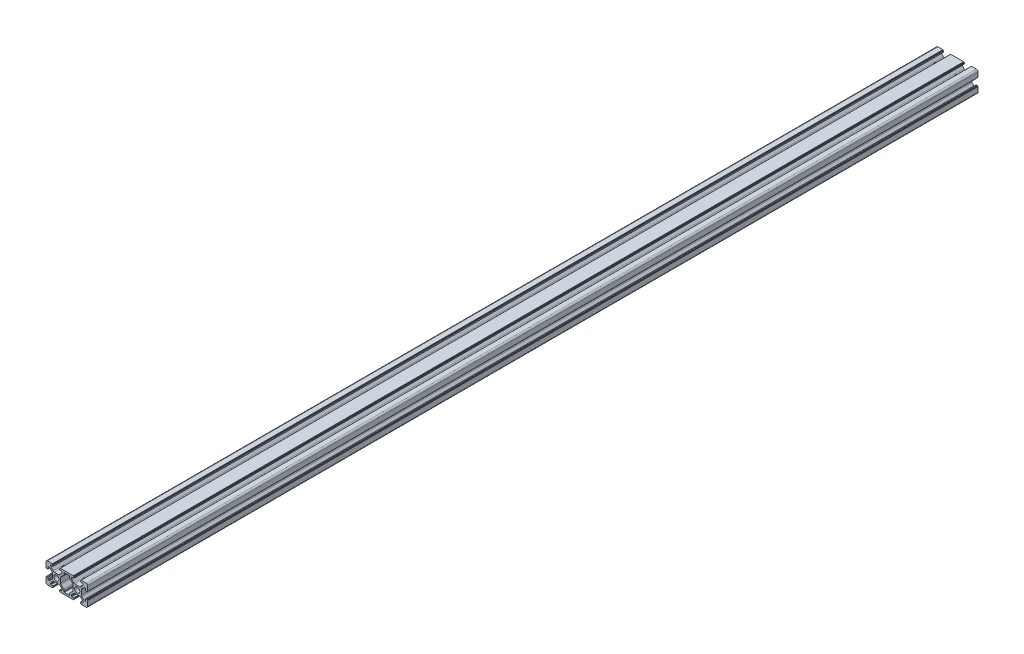
from build123d import *

# Parameters (mm, degrees)
SKETCH1_R                     = 2.5
BOSS_EXTRUDE2_DEPTH           = 856
SKETCH3_W                     = 2.75
SKETCH3_H                     = 13.9
M5_CLEARANCE_HOLE1_AT_2_COUNT = 2
M5_CLEARANCE_HOLE1_AT_2_PITCH = 20
M5_CLEARANCE_HOLE1_AT_3_COUNT = 2
M5_CLEARANCE_HOLE1_AT_3_PITCH = 838
M5_CLEARANCE_HOLE1_AT_4_COUNT = 2
M5_CLEARANCE_HOLE1_AT_4_PITCH = 838.238629508


with BuildPart() as part:
    # Sketch1 → Boss-Extrude2 (new body)
    with BuildSketch(Plane.XY):
        with BuildLine():
            Line((1.5, 0), (6.2, 0))
            ThreePointArc((6.2, 0), (6.341421356, 0.058578644), (6.4, 0.2))
            Line((6.4, 0.2), (6.4, 0.3))
            ThreePointArc((6.4, 0.3), (6.458578644, 0.441421356), (6.6, 0.5))
            Line((6.6, 0.5), (6.7, 0.5))
            ThreePointArc((6.7, 0.5), (6.841421356, 0.558578644), (6.9, 0.7))
            Line((6.9, 0.7), (6.9, 1.5))
            ThreePointArc((6.9, 1.5), (6.812132034, 1.712132034), (6.6, 1.8))
            Line((6.6, 1.8), (4.8, 1.8))
            ThreePointArc((4.8, 1.8), (4.587867966, 1.887867966), (4.5, 2.1))
            Line((4.5, 2.1), (4.5, 2.818019485))
            ThreePointArc((4.5, 2.818019485), (4.614180701, 3.392044633), (4.939339828, 3.878679656))
            Line((4.939339828, 3.878679656), (6.721320344, 5.660660172))
            ThreePointArc((6.721320344, 5.660660172), (7.207955367, 5.985819299), (7.781980515, 6.1))
            Line((7.781980515, 6.1), (12.218019485, 6.1))
            ThreePointArc((12.218019485, 6.1), (12.792044633, 5.985819299), (13.278679656, 5.660660172))
            Line((13.278679656, 5.660660172), (15.060660172, 3.878679656))
            ThreePointArc((15.060660172, 3.878679656), (15.385819299, 3.392044633), (15.5, 2.818019485))
            Line((15.5, 2.818019485), (15.5, 2.1))
            ThreePointArc((15.5, 2.1), (15.412132034, 1.887867966), (15.2, 1.8))
            Line((15.2, 1.8), (13.4, 1.8))
            ThreePointArc((13.4, 1.8), (13.187867966, 1.712132034), (13.1, 1.5))
            Line((13.1, 1.5), (13.1, 0.7))
            ThreePointArc((13.1, 0.7), (13.158578644, 0.558578644), (13.3, 0.5))
            Line((13.3, 0.5), (13.4, 0.5))
            ThreePointArc((13.4, 0.5), (13.541421356, 0.441421356), (13.6, 0.3))
            Line((13.6, 0.3), (13.6, 0.2))
            ThreePointArc((13.6, 0.2), (13.658578644, 0.058578644), (13.8, 0))
            Line((13.8, 0), (26.2, 0))
            ThreePointArc((26.2, 0), (26.341421356, 0.058578644), (26.4, 0.2))
            Line((26.4, 0.2), (26.4, 0.3))
            ThreePointArc((26.4, 0.3), (26.458578644, 0.441421356), (26.6, 0.5))
            Line((26.6, 0.5), (26.7, 0.5))
            ThreePointArc((26.7, 0.5), (26.841421356, 0.558578644), (26.9, 0.7))
            Line((26.9, 0.7), (26.9, 1.5))
            ThreePointArc((26.9, 1.5), (26.812132034, 1.712132034), (26.6, 1.8))
            Line((26.6, 1.8), (24.8, 1.8))
            ThreePointArc((24.8, 1.8), (24.587867966, 1.887867966), (24.5, 2.1))
            Line((24.5, 2.1), (24.5, 2.818019485))
            ThreePointArc((24.5, 2.818019485), (24.614180701, 3.392044633), (24.939339828, 3.878679656))
            Line((24.939339828, 3.878679656), (26.721320344, 5.660660172))
            ThreePointArc((26.721320344, 5.660660172), (27.207955367, 5.985819299), (27.781980515, 6.1))
            Line((27.781980515, 6.1), (32.218019485, 6.1))
            ThreePointArc((32.218019485, 6.1), (32.792044633, 5.985819299), (33.278679656, 5.660660172))
            Line((33.278679656, 5.660660172), (35.060660172, 3.878679656))
            ThreePointArc((35.060660172, 3.878679656), (35.385819299, 3.392044633), (35.5, 2.818019485))
            Line((35.5, 2.818019485), (35.5, 2.1))
            ThreePointArc((35.5, 2.1), (35.412132034, 1.887867966), (35.2, 1.8))
            Line((35.2, 1.8), (33.4, 1.8))
            ThreePointArc((33.4, 1.8), (33.187867966, 1.712132034), (33.1, 1.5))
            Line((33.1, 1.5), (33.1, 0.7))
            ThreePointArc((33.1, 0.7), (33.158578644, 0.558578644), (33.3, 0.5))
            Line((33.3, 0.5), (33.4, 0.5))
            ThreePointArc((33.4, 0.5), (33.541421356, 0.441421356), (33.6, 0.3))
            Line((33.6, 0.3), (33.6, 0.2))
            ThreePointArc((33.6, 0.2), (33.658578644, 0.058578644), (33.8, 0))
            Line((33.8, 0), (38.5, 0))
            ThreePointArc((38.5, 0), (39.560660172, 0.439339828), (40, 1.5))
            Line((40, 1.5), (40, 6.2))
            ThreePointArc((40, 6.2), (39.941421356, 6.341421356), (39.8, 6.4))
            Line((39.8, 6.4), (39.7, 6.4))
            ThreePointArc((39.7, 6.4), (39.558578644, 6.458578644), (39.5, 6.6))
            Line((39.5, 6.6), (39.5, 6.7))
            ThreePointArc((39.5, 6.7), (39.441421356, 6.841421356), (39.3, 6.9))
            Line((39.3, 6.9), (38.5, 6.9))
            ThreePointArc((38.5, 6.9), (38.287867966, 6.812132034), (38.2, 6.6))
            Line((38.2, 6.6), (38.2, 4.8))
            ThreePointArc((38.2, 4.8), (38.112132034, 4.587867966), (37.9, 4.5))
            Line((37.9, 4.5), (37.181980515, 4.5))
            ThreePointArc((37.181980515, 4.5), (36.607955367, 4.614180701), (36.121320344, 4.939339828))
            Line((36.121320344, 4.939339828), (34.339339828, 6.721320344))
            ThreePointArc((34.339339828, 6.721320344), (34.014180701, 7.207955367), (33.9, 7.781980515))
            Line((33.9, 7.781980515), (33.9, 12.218019485))
            ThreePointArc((33.9, 12.218019485), (34.014180701, 12.792044633), (34.339339828, 13.278679656))
            Line((34.339339828, 13.278679656), (36.121320344, 15.060660172))
            ThreePointArc((36.121320344, 15.060660172), (36.607955367, 15.385819299), (37.181980515, 15.5))
            Line((37.181980515, 15.5), (37.9, 15.5))
            ThreePointArc((37.9, 15.5), (38.112132034, 15.412132034), (38.2, 15.2))
            Line((38.2, 15.2), (38.2, 13.4))
            ThreePointArc((38.2, 13.4), (38.287867966, 13.187867966), (38.5, 13.1))
            Line((38.5, 13.1), (39.3, 13.1))
            ThreePointArc((39.3, 13.1), (39.441421356, 13.158578644), (39.5, 13.3))
            Line((39.5, 13.3), (39.5, 13.4))
            ThreePointArc((39.5, 13.4), (39.558578644, 13.541421356), (39.7, 13.6))
            Line((39.7, 13.6), (39.8, 13.6))
            ThreePointArc((39.8, 13.6), (39.941421356, 13.658578644), (40, 13.8))
            Line((40, 13.8), (40, 18.5))
            ThreePointArc((40, 18.5), (39.560660172, 19.560660172), (38.5, 20))
            Line((38.5, 20), (33.8, 20))
            ThreePointArc((33.8, 20), (33.658578644, 19.941421356), (33.6, 19.8))
            Line((33.6, 19.8), (33.6, 19.7))
            ThreePointArc((33.6, 19.7), (33.541421356, 19.558578644), (33.4, 19.5))
            Line((33.4, 19.5), (33.3, 19.5))
            ThreePointArc((33.3, 19.5), (33.158578644, 19.441421356), (33.1, 19.3))
            Line((33.1, 19.3), (33.1, 18.5))
            ThreePointArc((33.1, 18.5), (33.187867966, 18.287867966), (33.4, 18.2))
            Line((33.4, 18.2), (35.2, 18.2))
            ThreePointArc((35.2, 18.2), (35.412132034, 18.112132034), (35.5, 17.9))
            Line((35.5, 17.9), (35.5, 17.181980515))
            ThreePointArc((35.5, 17.181980515), (35.385819299, 16.607955367), (35.060660172, 16.121320344))
            Line((35.060660172, 16.121320344), (33.278679656, 14.339339828))
            ThreePointArc((33.278679656, 14.339339828), (32.792044633, 14.014180701), (32.218019485, 13.9))
            Line((32.218019485, 13.9), (27.781980515, 13.9))
            ThreePointArc((27.781980515, 13.9), (27.207955367, 14.014180701), (26.721320344, 14.339339828))
            Line((26.721320344, 14.339339828), (24.939339828, 16.121320344))
            ThreePointArc((24.939339828, 16.121320344), (24.614180701, 16.607955367), (24.5, 17.181980515))
            Line((24.5, 17.181980515), (24.5, 17.9))
            ThreePointArc((24.5, 17.9), (24.587867966, 18.112132034), (24.8, 18.2))
            Line((24.8, 18.2), (26.6, 18.2))
            ThreePointArc((26.6, 18.2), (26.812132034, 18.287867966), (26.9, 18.5))
            Line((26.9, 18.5), (26.9, 19.3))
            ThreePointArc((26.9, 19.3), (26.841421356, 19.441421356), (26.7, 19.5))
            Line((26.7, 19.5), (26.6, 19.5))
            ThreePointArc((26.6, 19.5), (26.458578644, 19.558578644), (26.4, 19.7))
            Line((26.4, 19.7), (26.4, 19.8))
            ThreePointArc((26.4, 19.8), (26.341421356, 19.941421356), (26.2, 20))
            Line((26.2, 20), (13.8, 20))
            ThreePointArc((13.8, 20), (13.658578644, 19.941421356), (13.6, 19.8))
            Line((13.6, 19.8), (13.6, 19.7))
            ThreePointArc((13.6, 19.7), (13.541421356, 19.558578644), (13.4, 19.5))
            Line((13.4, 19.5), (13.3, 19.5))
            ThreePointArc((13.3, 19.5), (13.158578644, 19.441421356), (13.1, 19.3))
            Line((13.1, 19.3), (13.1, 18.2))
            Line((13.1, 18.2), (15.3, 18.2))
            ThreePointArc((15.3, 18.2), (15.512132034, 18.112132034), (15.6, 17.9))
            Line((15.6, 17.9), (15.6, 17.281980515))
            ThreePointArc((15.6, 17.281980515), (15.485819299, 16.707955367), (15.160660172, 16.221320344))
            Line((15.160660172, 16.221320344), (13.278679656, 14.339339828))
            ThreePointArc((13.278679656, 14.339339828), (12.792044633, 14.014180701), (12.218019485, 13.9))
            Line((12.218019485, 13.9), (7.986375635, 13.9))
            ThreePointArc((7.986375635, 13.9), (7.393381044, 14.022191082), (6.896997987, 14.36885678))
            Line((6.896997987, 14.36885678), (4.910622352, 16.467414163))
            ThreePointArc((4.910622352, 16.467414163), (4.606431474, 16.943609851), (4.5, 17.498557383))
            Line((4.5, 17.498557383), (4.5, 17.9))
            ThreePointArc((4.5, 17.9), (4.587867966, 18.112132034), (4.8, 18.2))
            Line((4.8, 18.2), (6.9, 18.2))
            Line((6.9, 18.2), (6.9, 19.3))
            ThreePointArc((6.9, 19.3), (6.841421356, 19.441421356), (6.7, 19.5))
            Line((6.7, 19.5), (6.6, 19.5))
            ThreePointArc((6.6, 19.5), (6.458578644, 19.558578644), (6.4, 19.7))
            Line((6.4, 19.7), (6.4, 19.8))
            ThreePointArc((6.4, 19.8), (6.341421356, 19.941421356), (6.2, 20))
            Line((6.2, 20), (1.5, 20))
            ThreePointArc((1.5, 20), (0.439339828, 19.560660172), (0, 18.5))
            Line((0, 18.5), (0, 13.8))
            ThreePointArc((0, 13.8), (0.058578644, 13.658578644), (0.2, 13.6))
            Line((0.2, 13.6), (0.3, 13.6))
            ThreePointArc((0.3, 13.6), (0.441421356, 13.541421356), (0.5, 13.4))
            Line((0.5, 13.4), (0.5, 13.3))
            ThreePointArc((0.5, 13.3), (0.558578644, 13.158578644), (0.7, 13.1))
            Line((0.7, 13.1), (1.5, 13.1))
            ThreePointArc((1.5, 13.1), (1.712132034, 13.187867966), (1.8, 13.4))
            Line((1.8, 13.4), (1.8, 15.2))
            ThreePointArc((1.8, 15.2), (1.887867966, 15.412132034), (2.1, 15.5))
            Line((2.1, 15.5), (2.818019485, 15.5))
            ThreePointArc((2.818019485, 15.5), (3.392044633, 15.385819299), (3.878679656, 15.060660172))
            Line((3.878679656, 15.060660172), (5.660660172, 13.278679656))
            ThreePointArc((5.660660172, 13.278679656), (5.985819299, 12.792044633), (6.1, 12.218019485))
            Line((6.1, 12.218019485), (6.1, 7.781980515))
            ThreePointArc((6.1, 7.781980515), (5.985819299, 7.207955367), (5.660660172, 6.721320344))
            Line((5.660660172, 6.721320344), (3.878679656, 4.939339828))
            ThreePointArc((3.878679656, 4.939339828), (3.392044633, 4.614180701), (2.818019485, 4.5))
            Line((2.818019485, 4.5), (2.1, 4.5))
            ThreePointArc((2.1, 4.5), (1.887867966, 4.587867966), (1.8, 4.8))
            Line((1.8, 4.8), (1.8, 6.6))
            ThreePointArc((1.8, 6.6), (1.712132034, 6.812132034), (1.5, 6.9))
            Line((1.5, 6.9), (0.7, 6.9))
            ThreePointArc((0.7, 6.9), (0.558578644, 6.841421356), (0.5, 6.7))
            Line((0.5, 6.7), (0.5, 6.6))
            ThreePointArc((0.5, 6.6), (0.441421356, 6.458578644), (0.3, 6.4))
            Line((0.3, 6.4), (0.2, 6.4))
            ThreePointArc((0.2, 6.4), (0.058578644, 6.341421356), (0, 6.2))
            Line((0, 6.2), (0, 1.5))
            ThreePointArc((0, 1.5), (0.439339828, 0.439339828), (1.5, 0))
        make_face()
        with Locations((10, 10)):
            Circle(SKETCH1_R, mode=Mode.SUBTRACT)
        with Locations((30, 10)):
            Circle(SKETCH1_R, mode=Mode.SUBTRACT)
        with BuildLine():
            Line((17.6, 1.8), (22.4, 1.8))
            ThreePointArc((22.4, 1.8), (22.612132034, 1.887867966), (22.7, 2.1))
            Line((22.7, 2.1), (22.7, 3.139339828))
            ThreePointArc((22.7, 3.139339828), (22.814180701, 3.713364977), (23.139339828, 4.2))
            Line((23.139339828, 4.2), (25.660660172, 6.721320344))
            ThreePointArc((25.660660172, 6.721320344), (25.985819299, 7.207955367), (26.1, 7.781980515))
            Line((26.1, 7.781980515), (26.1, 12.218019485))
            ThreePointArc((26.1, 12.218019485), (25.985819299, 12.792044633), (25.660660172, 13.278679656))
            Line((25.660660172, 13.278679656), (23.139339828, 15.8))
            ThreePointArc((23.139339828, 15.8), (22.814180701, 16.286635023), (22.7, 16.860660172))
            Line((22.7, 16.860660172), (22.7, 17.9))
            ThreePointArc((22.7, 17.9), (22.612132034, 18.112132034), (22.4, 18.2))
            Line((22.4, 18.2), (17.6, 18.2))
            ThreePointArc((17.6, 18.2), (17.387867966, 18.112132034), (17.3, 17.9))
            Line((17.3, 17.9), (17.3, 16.860660172))
            ThreePointArc((17.3, 16.860660172), (17.185819299, 16.286635023), (16.860660172, 15.8))
            Line((16.860660172, 15.8), (14.339339828, 13.278679656))
            ThreePointArc((14.339339828, 13.278679656), (14.014180701, 12.792044633), (13.9, 12.218019485))
            Line((13.9, 12.218019485), (13.9, 7.781980515))
            ThreePointArc((13.9, 7.781980515), (14.014180701, 7.207955367), (14.339339828, 6.721320344))
            Line((14.339339828, 6.721320344), (16.860660172, 4.2))
            ThreePointArc((16.860660172, 4.2), (17.185819299, 3.713364977), (17.3, 3.139339828))
            Line((17.3, 3.139339828), (17.3, 2.1))
            ThreePointArc((17.3, 2.1), (17.387867966, 1.887867966), (17.6, 1.8))
        make_face(mode=Mode.SUBTRACT)
    extrude(amount=BOSS_EXTRUDE2_DEPTH)

    # Sketch3 → M5 Clearance Hole1 (revolve, cut)
    with BuildSketch(Plane(origin=(30, 6.1, 847), x_dir=(0, 0, -1), z_dir=(1, 0, 0))):
        with Locations((1.375, 6.95)):
            Rectangle(SKETCH3_W, SKETCH3_H)
    m5_clearance_hole1 = revolve(axis=Axis((30, -0.25, 847), (0, 1, 0)), mode=Mode.SUBTRACT)

    # M5 Clearance Hole1 at 2: M5 Clearance Hole1 ×2
    with Locations(*[(-i * M5_CLEARANCE_HOLE1_AT_2_PITCH, 0, 0) for i in range(1, M5_CLEARANCE_HOLE1_AT_2_COUNT)]):
        add(m5_clearance_hole1, mode=Mode.SUBTRACT)

    # M5 Clearance Hole1 at 3: M5 Clearance Hole1 ×2
    with Locations(*[(0, 0, -i * M5_CLEARANCE_HOLE1_AT_3_PITCH) for i in range(1, M5_CLEARANCE_HOLE1_AT_3_COUNT)]):
        add(m5_clearance_hole1, mode=Mode.SUBTRACT)

    # M5 Clearance Hole1 at 4: M5 Clearance Hole1 ×2
    with Locations(*[Vector(-0.023859554, 0, -0.99971532) * (i * M5_CLEARANCE_HOLE1_AT_4_PITCH) for i in range(1, M5_CLEARANCE_HOLE1_AT_4_COUNT)]):
        add(m5_clearance_hole1, mode=Mode.SUBTRACT)


solid = part.part
